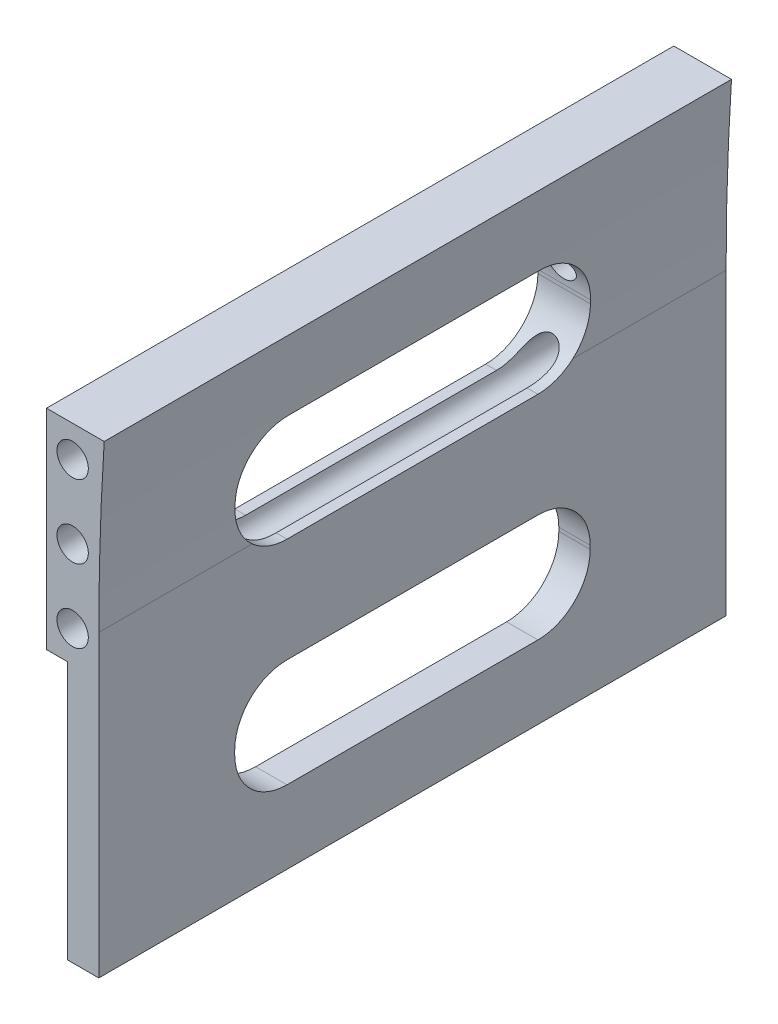
from build123d import *

# Parameters (mm, degrees)
RESSALTO_EXTRUS_O1_DEPTH = 60
ESBO_O7_R                = 2.076684074
CORTE_EXTRUS_O5_DEPTH    = 61
ESBO_O8_W                = 84.528747457
ESBO_O8_H                = 37.806532702
CORTE_EXTRUS_O6_DEPTH    = 61
ESBO_O9_W                = 39.370764713
ESBO_O9_H                = 9.06161947
CORTE_EXTRUS_O7_DEPTH    = 61
ESBO_O10_W               = 32.42010131
ESBO_O10_H               = 62.029224545
CORTE_EXTRUS_O8_DEPTH    = 61
ESBO_O12_W               = 17.69499929
ESBO_O12_H               = 9
CORTE_EXTRUS_O10_DEPTH   = 61
ESBO_O13_W               = 2
ESBO_O13_H               = 24.699383264
CORTE_EXTRUS_O11_DEPTH   = 61
CORTE_EXTRUS_O12_DEPTH   = 6.517415369
ESBO_O15_R               = 1.5
CORTE_EXTRUS_O13_DEPTH   = 61.0000001


with BuildPart() as part:
    # Esboço1 → Ressalto-extrusão1 (new body)
    with BuildSketch(Plane.XY):
        with BuildLine():
            Line((13.569146061, 27.715579822), (13.569146061, 56.338894978))
            ThreePointArc((13.569146061, 56.338894978), (13.884544414, 68.892766914), (14.829943665, 81.414963086))
            ThreePointArc((14.829943665, 81.414963086), (11.193742071, 116.066691762), (-16.576524471, 95.024435265))
            Line((-16.576524471, 95.024435265), (-16.487894969, 94.437265709))
            Line((-16.487894969, 94.437265709), (-16.369382775, 93.652123615))
            ThreePointArc((-16.369382775, 93.652123615), (-14.270188159, 75.047972701), (-13.569146061, 56.338894978))
            Line((-13.569146061, 56.338894978), (-13.569146061, 27.715579822))
            ThreePointArc((-13.569146061, 27.715579822), (0, 21.02683783), (13.569146061, 27.715579822))
        make_face()
    extrude(amount=RESSALTO_EXTRUS_O1_DEPTH)

    # Esboço7 → Corte-extrusão5 (cut, through all)
    with BuildSketch(Plane(origin=(0, 0, 0), x_dir=(-1, 0, 0), z_dir=(0, 0, -1))):
        with Locations((-0.267564972, 95.19)):
            Circle(ESBO_O7_R)
    extrude(amount=-CORTE_EXTRUS_O5_DEPTH, mode=Mode.SUBTRACT)

    # Esboço8 → Corte-extrusão6 (cut, through all)
    with BuildSketch(Plane.XY.offset(60)):
        with Locations((-3.694100087, 100.318229437)):
            Rectangle(ESBO_O8_W, ESBO_O8_H)
    extrude(amount=-CORTE_EXTRUS_O6_DEPTH, mode=Mode.SUBTRACT)

    # Esboço9 → Corte-extrusão7 (cut, through all)
    with BuildSketch(Plane.XY.offset(60)):
        with Locations((-6.116236296, 23.184770087)):
            Rectangle(ESBO_O9_W, ESBO_O9_H)
    extrude(amount=-CORTE_EXTRUS_O7_DEPTH, mode=Mode.SUBTRACT)

    # Esboço10 → Corte-extrusão8 (cut, through all)
    with BuildSketch(Plane.XY.offset(60)):
        with Locations((-7.640904594, 58.730192094)):
            Rectangle(ESBO_O10_W, ESBO_O10_H)
    extrude(amount=-CORTE_EXTRUS_O8_DEPTH, mode=Mode.SUBTRACT)

    # Esboço12 → Corte-extrusão10 (cut, through all)
    with BuildSketch(Plane.XY.offset(60)):
        with Locations((10.676364632, 76.914963086)):
            Rectangle(ESBO_O12_W, ESBO_O12_H)
    extrude(amount=-CORTE_EXTRUS_O10_DEPTH, mode=Mode.SUBTRACT)

    # Esboço13 → Corte-extrusão11 (cut, through all)
    with BuildSketch(Plane.XY.offset(60)):
        with Locations((9.569146061, 40.065271454)):
            Rectangle(ESBO_O13_W, ESBO_O13_H)
    extrude(amount=-CORTE_EXTRUS_O11_DEPTH, mode=Mode.SUBTRACT)

    # Esboço14 → Corte-extrusão12 (cut, through all)
    with BuildSketch(Plane.ZY.offset(-8.569146061)):
        with BuildLine():
            Line((42, 55.065579822), (18, 55.065579822))
            ThreePointArc((18, 55.065579822), (14.464466094, 56.530045916), (13, 60.065579822))
            Line((13, 60.065579822), (13, 60.414963086))
            ThreePointArc((13, 60.414963086), (14.464466094, 63.950496992), (18, 65.414963086))
            Line((18, 65.414963086), (42, 65.414963086))
            ThreePointArc((42, 65.414963086), (45.535533906, 63.950496992), (47, 60.414963086))
            Line((47, 60.414963086), (47, 60.065579822))
            ThreePointArc((47, 60.065579822), (45.535533906, 56.530045916), (42, 55.065579822))
        make_face()
        with BuildLine():
            Line((42, 34.715579822), (18, 34.715579822))
            ThreePointArc((18, 34.715579822), (14.464466094, 36.180045916), (13, 39.715579822))
            Line((13, 39.715579822), (13, 40.065579822))
            ThreePointArc((13, 40.065579822), (14.464466094, 43.601113728), (18, 45.065579822))
            Line((18, 45.065579822), (42, 45.065579822))
            ThreePointArc((42, 45.065579822), (45.535533906, 43.601113728), (47, 40.065579822))
            Line((47, 40.065579822), (47, 39.715579822))
            ThreePointArc((47, 39.715579822), (45.535533906, 36.180045916), (42, 34.715579822))
        make_face()
    extrude(amount=-CORTE_EXTRUS_O12_DEPTH, mode=Mode.SUBTRACT)

    # Esboço15 → Corte-extrusão13 (cut, through all)
    with BuildSketch(Plane.XY.offset(60)):
        with Locations((11.069146061, 69.414963086)):
            Circle(ESBO_O15_R)
        with Locations((11.069146061, 62.414963086)):
            Circle(ESBO_O15_R)
        with Locations((11.069146061, 55.414963086)):
            Circle(ESBO_O15_R)
    extrude(amount=-CORTE_EXTRUS_O13_DEPTH, mode=Mode.SUBTRACT)


solid = part.part
